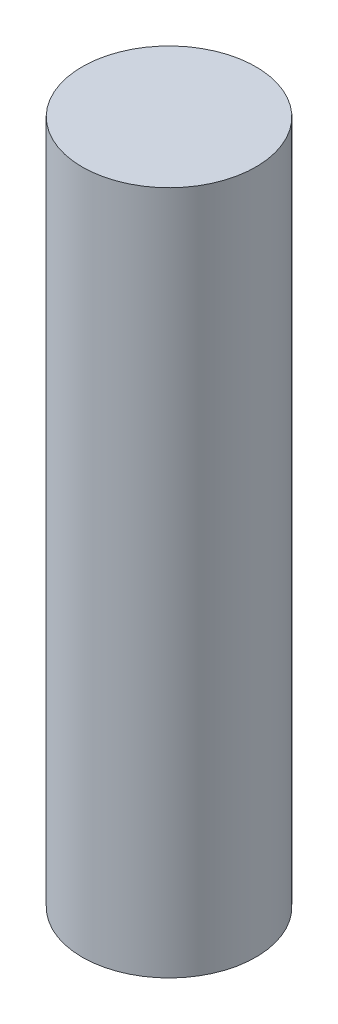
from build123d import *

# Parameters (mm, degrees)
SKETCH2_R           = 12.5
BOSS_EXTRUDE1_DEPTH = 98.5
SKETCH3_R           = 3.175
CUT_EXTRUDE1_DEPTH  = 10


with BuildPart() as part:
    # Sketch2 → Boss-Extrude1 (new body)
    with BuildSketch(Plane(origin=(0, 0, 0), x_dir=(1, 0, 0), z_dir=(0, 1, 0))):
        Circle(SKETCH2_R)
    extrude(amount=BOSS_EXTRUDE1_DEPTH)

    # Sketch3 → Cut-Extrude1 (cut)
    with BuildSketch(Plane.XZ):
        Circle(SKETCH3_R)
    extrude(amount=-CUT_EXTRUDE1_DEPTH, mode=Mode.SUBTRACT)


solid = part.part
